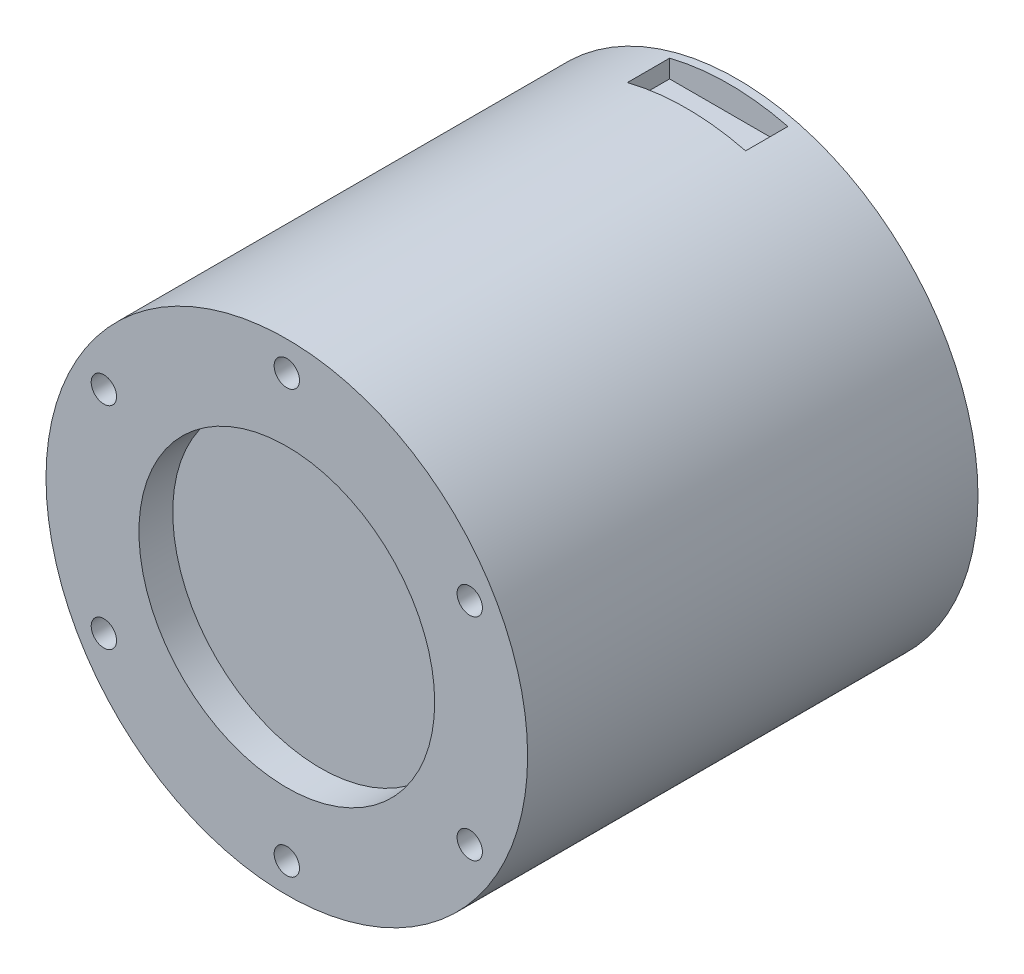
from build123d import *

# Parameters (mm, degrees)
SKETCH_1_R          = 28.5
EXTRUDE_1_DEPTH     = 53.3
SKETCH_2_R          = 17.5
CUT_EXTRUDE_2_DEPTH = 4
SKETCH_2_5_R        = 1.5
CUT_EXTRUDE_3_DEPTH = 5
SKETCH_4_R          = 1.5
CUT_EXTRUDE_4_DEPTH = 4
SKETCH_9_W          = 14
SKETCH_9_H          = 5
CUT_EXTRUDE_6_DEPTH = 3
SKETCH_10_W         = 8
SKETCH_10_H         = 8
CUT_EXTRUDE_7_DEPTH = 3


with BuildPart() as part:
    # 草图1 → 凸台-拉伸1 (new body)
    with BuildSketch(Plane.XY):
        Circle(SKETCH_1_R)
    extrude(amount=EXTRUDE_1_DEPTH)

    # 草图2 → 切除-拉伸2 (cut)
    with BuildSketch(Plane.XY.offset(53.3)):
        Circle(SKETCH_2_R)
    extrude(amount=-CUT_EXTRUDE_2_DEPTH, mode=Mode.SUBTRACT)

    # 草图2<5> → 切除-拉伸3 (cut)
    with BuildSketch(Plane.XY.offset(53.3)):
        with Locations((0, 25)):
            Circle(SKETCH_2_5_R)
        with Locations((21.650635095, 12.5)):
            Circle(SKETCH_2_5_R)
        with Locations((21.650635095, -12.5)):
            Circle(SKETCH_2_5_R)
        with Locations((0, -25)):
            Circle(SKETCH_2_5_R)
        with Locations((-21.650635095, -12.5)):
            Circle(SKETCH_2_5_R)
        with Locations((-21.650635095, 12.5)):
            Circle(SKETCH_2_5_R)
    extrude(amount=-CUT_EXTRUDE_3_DEPTH, mode=Mode.SUBTRACT)

    # 草图4 → 切除-拉伸4 (cut)
    with BuildSketch(Plane(origin=(0, 0, 0), x_dir=(-1, 0, 0), z_dir=(0, 0, -1))):
        with Locations((13.435028843, 13.435028843)):
            Circle(SKETCH_4_R)
        with Locations((-13.435028843, 13.435028843)):
            Circle(SKETCH_4_R)
        with Locations((13.435028843, -13.435028843)):
            Circle(SKETCH_4_R)
        with Locations((-13.435028843, -13.435028843)):
            Circle(SKETCH_4_R)
    extrude(amount=-CUT_EXTRUDE_4_DEPTH, mode=Mode.SUBTRACT)

    # 草图9 → 切除-拉伸6 (cut)
    with BuildSketch(Plane(origin=(0, 28.5, 0), x_dir=(1, 0, 0), z_dir=(0, 1, 0))):
        with Locations((0, -3.5)):
            Rectangle(SKETCH_9_W, SKETCH_9_H)
    cut_extrude_6 = extrude(amount=-CUT_EXTRUDE_6_DEPTH, mode=Mode.SUBTRACT)

    # 镜向1: 切除-拉伸6 across plane
    add(cut_extrude_6.mirror(Plane.ZX), mode=Mode.SUBTRACT)

    # 草图10 → 切除-拉伸7 (cut)
    with BuildSketch(Plane(origin=(-28.5, 0, 0), x_dir=(0, 0, -1), z_dir=(1, 0, 0))):
        with Locations((-5, 0)):
            Rectangle(SKETCH_10_W, SKETCH_10_H)
    extrude(amount=CUT_EXTRUDE_7_DEPTH, mode=Mode.SUBTRACT)


solid = part.part
